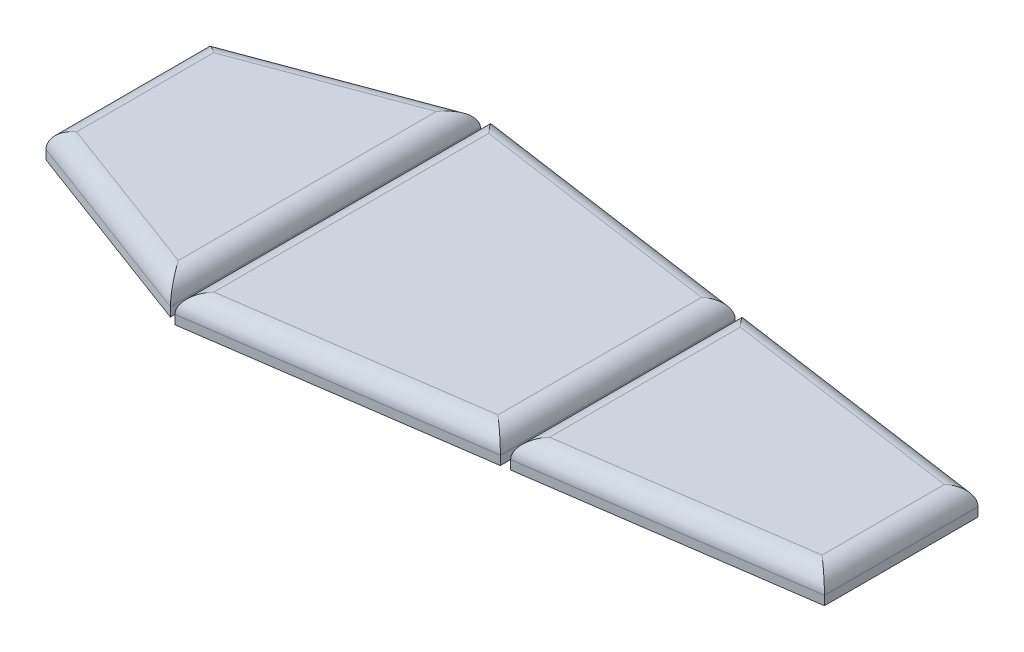
from build123d import *

# Parameters (mm, degrees)
BOSS_EXTRUDE3_DEPTH = 76.2
BOSS_EXTRUDE4_DEPTH = 76.2
BOSS_EXTRUDE5_DEPTH = 76.2
FILLET2_R           = 50.8
FILLET3_R           = 50.8
FILLET4_R           = 50.8


with BuildPart() as part:
    # Sketch2 → Boss-Extrude3 (new body)
    with BuildSketch(Plane(origin=(0, 14.2875, 0), x_dir=(1, 0, 0), z_dir=(0, 1, 0))):
        Polygon((-1148.128331341, 239.454600148), (-589.328331341, 447.775240148), (-589.328331341, -425.648013671), (-1148.128331341, -217.313403671), align=None)
    extrude(amount=BOSS_EXTRUDE3_DEPTH)

    # Fillet2
    fillet2_edges = [part.edges().sort_by_distance(p)[0] for p in [
        (-589.328331341, 90.4875, -11.063613239),
        (-868.728331341, 90.4875, -343.614920148),
        (-1148.128331341, 90.4875, -11.070598239),
        (-868.728331341, 90.4875, 321.480708671),
    ]]
    fillet(fillet2_edges, radius=FILLET2_R)


with BuildPart() as body_2:
    # Sketch3 → Boss-Extrude4 (new body)
    with BuildSketch(Plane(origin=(0, 14.2875, 0), x_dir=(1, 0, 0), z_dir=(0, 1, 0))):
        Polygon((-563.928331341, 453.518833879), (-563.928331341, -438.013880611), (237.766686559, -323.055440208), (237.766686559, 338.568102081), align=None)
    extrude(amount=BOSS_EXTRUDE4_DEPTH)

    # Fillet3
    fillet3_edges = [body_2.edges().sort_by_distance(p)[0] for p in [
        (-163.080822391, 90.4875, 380.53466041),
        (237.766686559, 90.4875, -7.756330937),
        (-163.080822391, 90.4875, -396.04346798),
        (-563.928331341, 90.4875, -7.752476634),
    ]]
    fillet(fillet3_edges, radius=FILLET3_R)


with BuildPart() as body_3:
    # Sketch4 → Boss-Extrude5 (new body)
    with BuildSketch(Plane(origin=(0, 14.2875, 0), x_dir=(1, 0, 0), z_dir=(0, 1, 0))):
        Polygon((263.166686559, 334.92613285), (263.166686559, -319.413226747), (1036.271668659, -208.554432534), (1036.271668659, 224.07477234), align=None)
    extrude(amount=BOSS_EXTRUDE5_DEPTH)

    # Fillet4
    fillet4_edges = [body_3.edges().sort_by_distance(p)[0] for p in [
        (649.719177609, 90.4875, 263.983829641),
        (1036.271668659, 90.4875, -7.760169903),
        (649.719177609, 90.4875, -279.500452595),
        (263.166686559, 90.4875, -7.756453052),
    ]]
    fillet(fillet4_edges, radius=FILLET4_R)


solid = Compound([part.part, body_2.part, body_3.part])
